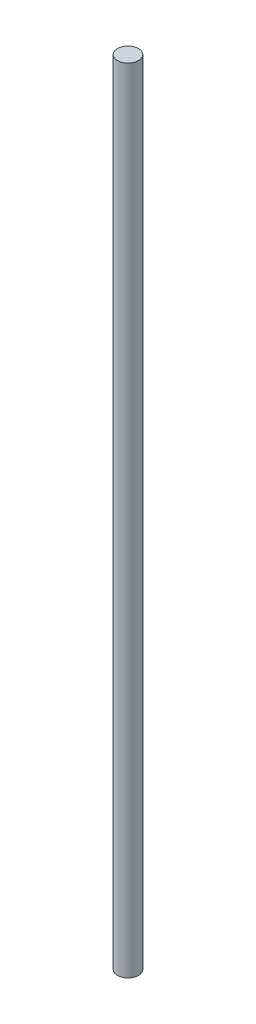
from build123d import *

# Parameters (mm, degrees)
CROQUIS1_R = 6.35


with BuildPart() as part:
    # Barrer1: sweep along a path in Croquis2
    with BuildLine(Plane.XY) as barrer1_path:
        Line((0, 0), (0, 480))
    # Croquis1 → Barrer1 (sweep)
    with BuildSketch(Plane(origin=(0, 0, 0), x_dir=(1, 0, 0), z_dir=(0, 1, 0))):
        Circle(CROQUIS1_R)
    sweep(path=barrer1_path.line)


solid = part.part
